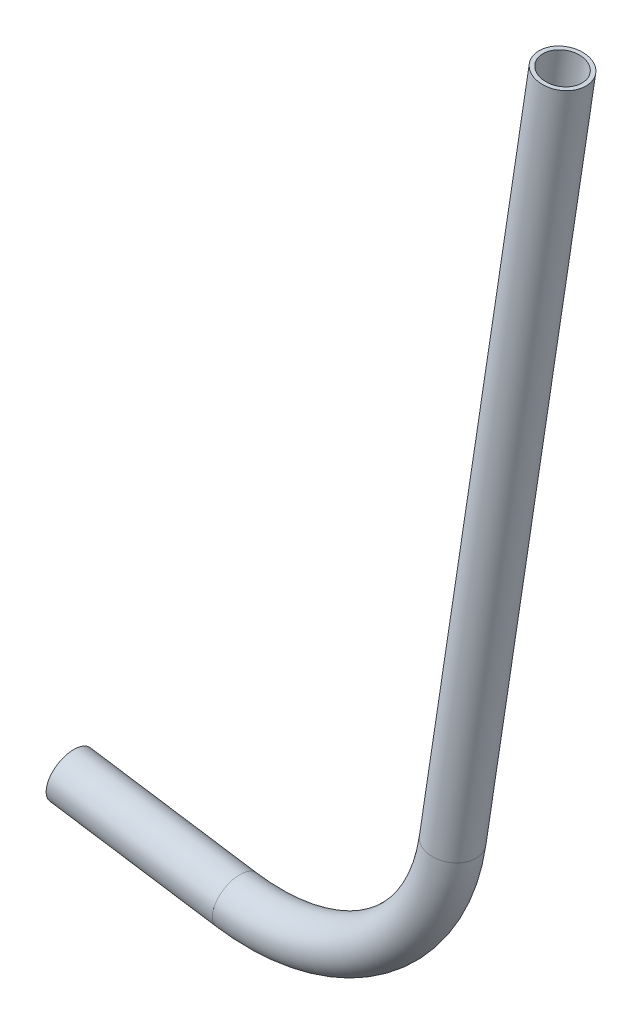
from build123d import *

# Parameters (mm, degrees)
SKETCH11_R                = 6.35
SKETCH11_R_2              = 5.2832
PIPE_0_5_SCH_40_1_DEPTH   = 44.95961314
SKETCH11_ON_SEGMENT_2_R   = 6.35
SKETCH11_ON_SEGMENT_2_R_2 = 5.2832
PIPE_0_5_SCH_40_1_2_ANGLE = 90
SKETCH11_ON_SEGMENT_3_R   = 6.35
SKETCH11_ON_SEGMENT_3_R_2 = 5.2832
PIPE_0_5_SCH_40_1_3_DEPTH = 195.80541507


with BuildPart() as part:
    # Sketch11 → Pipe 0.5 SCH 40(1) (new body)
    with BuildSketch(Plane(origin=(29.590443683, 130.712980208, 0), x_dir=(0.15013773190138419, 0.9886650906447078, 0), z_dir=(0.9886650906447078, -0.15013773190138419, 0))):
        Circle(SKETCH11_R)
        Circle(SKETCH11_R_2, mode=Mode.SUBTRACT)
    extrude(amount=PIPE_0_5_SCH_40_1_DEPTH)


with BuildPart() as body_2:
    # Sketch11 on segment 2 (carried to the start of arc 2) → Pipe 0.5 SCH 40_1 2 (revolve)
    with BuildSketch(Plane(origin=(74.040443683, 123.962845864, 0), x_dir=(0.150137732, 0.988665091, 0), z_dir=(0.988665091, -0.150137732, 0))):
        Circle(SKETCH11_ON_SEGMENT_2_R)
        Circle(SKETCH11_ON_SEGMENT_2_R_2, mode=Mode.SUBTRACT)
    revolve(axis=Axis((81.667440463, 174.187032469, 0), (0, 0, 1)), revolution_arc=PIPE_0_5_SCH_40_1_2_ANGLE)


with BuildPart() as body_3:
    # Sketch11 on segment 3 (carried to segment 3) → Pipe 0.5 SCH 40_1 3 (new body)
    with BuildSketch(Plane(origin=(131.891627068, 166.560035688, 0), x_dir=(-0.988665091, 0.150137732, 0), z_dir=(0.150137732, 0.988665091, 0))):
        Circle(SKETCH11_ON_SEGMENT_3_R)
        Circle(SKETCH11_ON_SEGMENT_3_R_2, mode=Mode.SUBTRACT)
    extrude(amount=PIPE_0_5_SCH_40_1_3_DEPTH)


solid = Compound([part.part, body_2.part, body_3.part])
